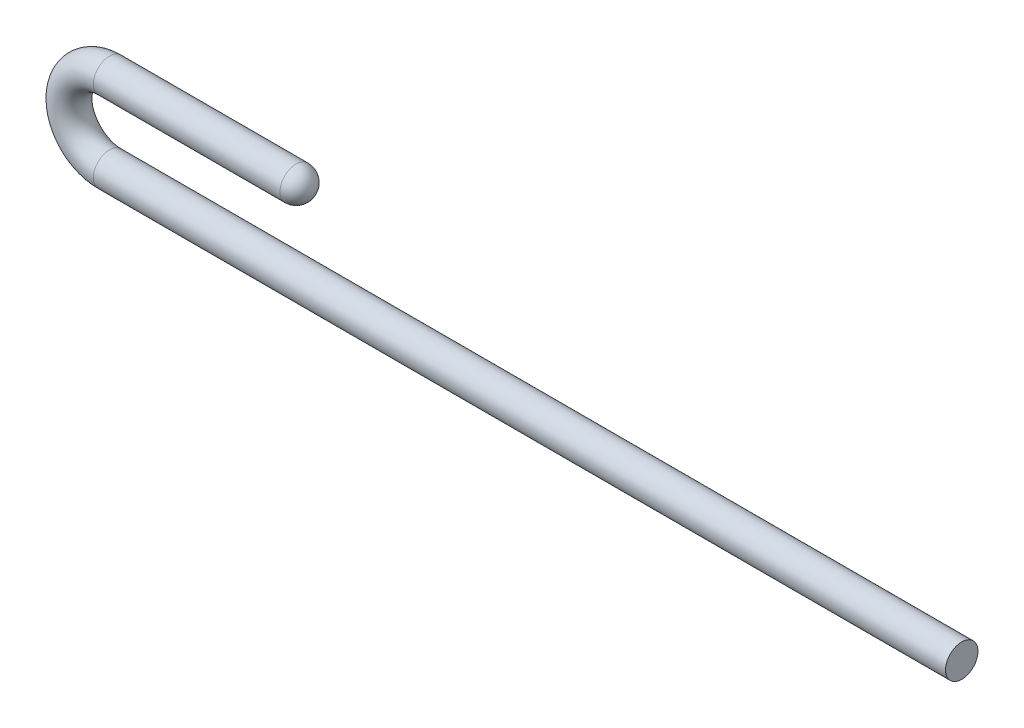
from build123d import *

# Parameters (mm, degrees)
SKETCH2_R = 0.4
FILLET1_R = 0.4


with BuildPart() as part:
    # Sweep1: sweep along a path in Sketch1
    with BuildLine(Plane.XY) as sweep1_path:
        Line((0, 0), (-21, 0))
        ThreePointArc((-21, 0), (-22, 1), (-21, 2))
        Line((-21, 2), (-16, 2))
    # Sketch2 → Sweep1 (sweep)
    with BuildSketch(Plane(origin=(0, 0, 0), x_dir=(0, 0, -1), z_dir=(1, 0, 0))):
        Circle(SKETCH2_R)
    sweep(path=sweep1_path.line)

    # Fillet1
    fillet1_edges = [part.edges().sort_by_distance(p)[0] for p in [
        (-16, 2, 0.4),
    ]]
    fillet(fillet1_edges, radius=FILLET1_R)


solid = part.part
